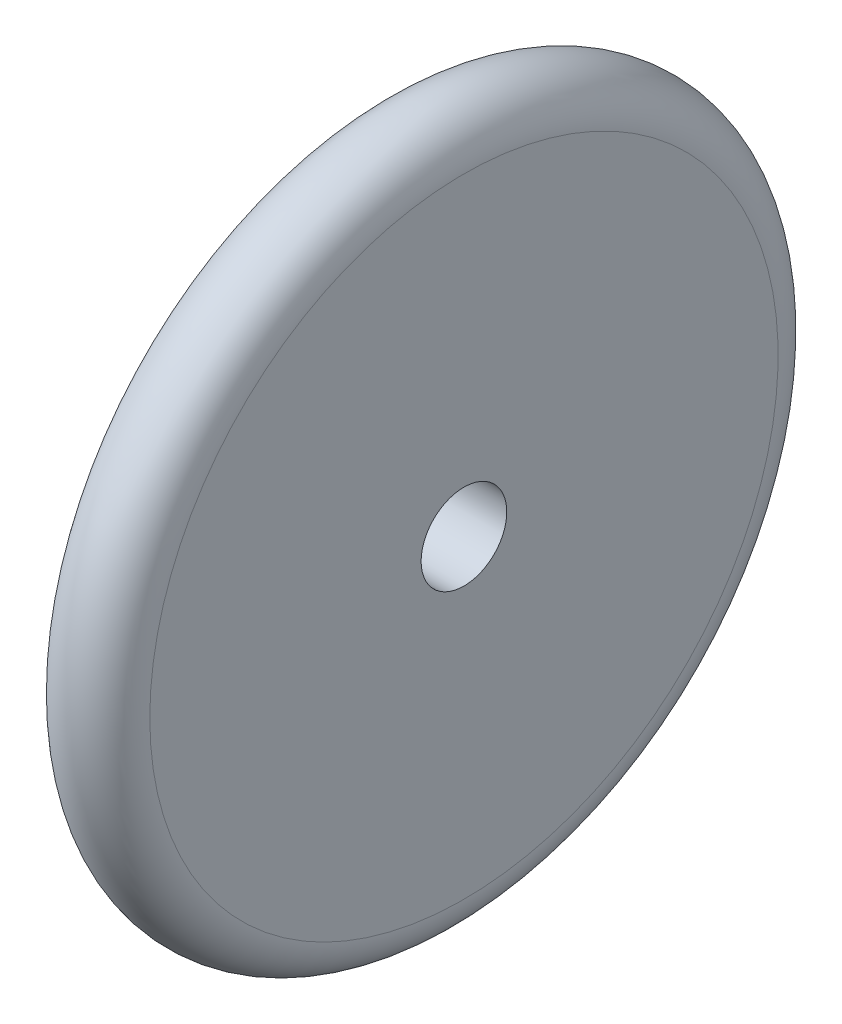
from build123d import *


with BuildPart() as part:
    # Sketch1 → Revolve1 (revolve)
    with BuildSketch(Plane.XY):
        with BuildLine():
            ThreePointArc((0, 110), (15, 125), (30, 110))
            Line((30, 110), (30, 15))
            Line((30, 15), (0, 15))
            Line((0, 15), (0, 110))
        make_face()
    revolve(axis=Axis((0, 0, 0), (1, 0, 0)))


solid = part.part
